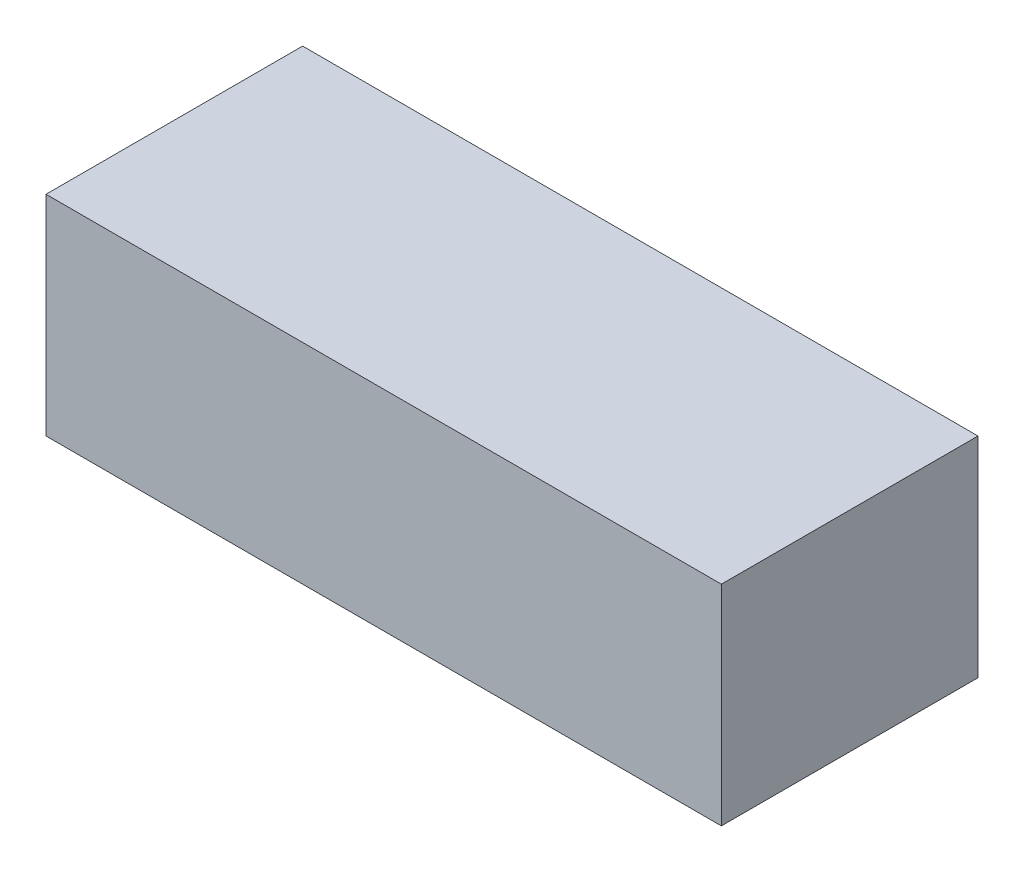
from build123d import *

# Parameters (mm, degrees)
SKETCH1_W           = 200
SKETCH1_H           = 76
BOSS_EXTRUDE1_DEPTH = 62


with BuildPart() as part:
    # Sketch1 → Boss-Extrude1 (new body)
    with BuildSketch(Plane(origin=(0, 0, 0), x_dir=(1, 0, 0), z_dir=(0, 1, 0))):
        with Locations((100, 38)):
            Rectangle(SKETCH1_W, SKETCH1_H)
    extrude(amount=BOSS_EXTRUDE1_DEPTH)


solid = part.part
